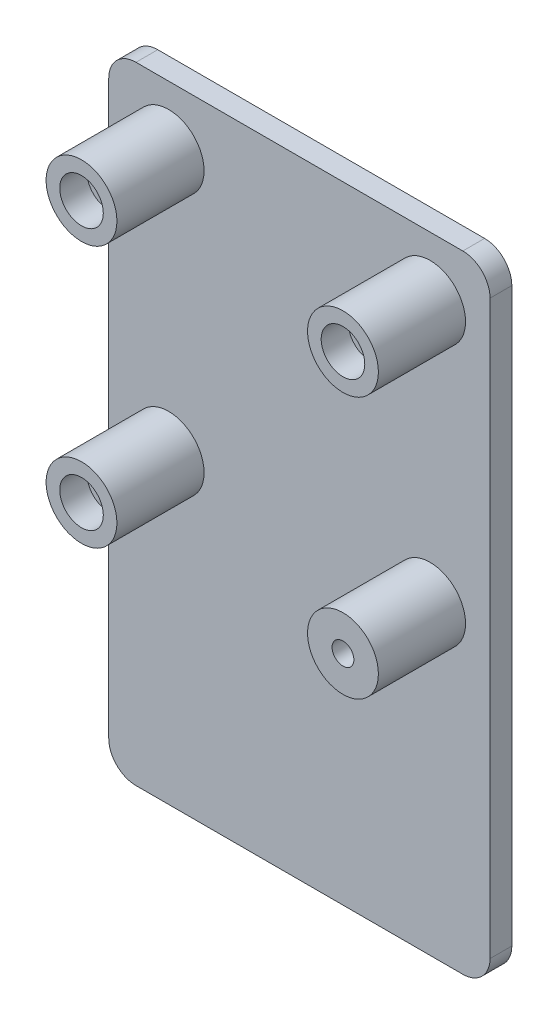
from build123d import *

# Parameters (mm, degrees)
SKETCH1_R           = 6.5
BOSS_EXTRUDE1_DEPTH = 4
SKETCH1_5_R         = 6.5
SKETCH1_5_R_2       = 4
SKETCH1_5_R_3       = 2
BOSS_EXTRUDE2_DEPTH = 20
CUT_EXTRUDE1_START  = 20
SKETCH1_6_R         = 4
SKETCH1_6_R_2       = 2
CUT_EXTRUDE1_DEPTH  = 5


with BuildPart() as part:
    # Sketch1 → Boss-Extrude1 (new body)
    with BuildSketch(Plane.XY):
        with BuildLine():
            Line((-30, 35), (30, 35))
            ThreePointArc((30, 35), (33.535533906, 33.535533906), (35, 30))
            Line((35, 30), (35, -75))
            ThreePointArc((35, -75), (33.535533906, -78.535533906), (30, -80))
            Line((30, -80), (-30, -80))
            ThreePointArc((-30, -80), (-33.535533906, -78.535533906), (-35, -75))
            Line((-35, -75), (-35, 30))
            ThreePointArc((-35, 30), (-33.535533906, 33.535533906), (-30, 35))
        make_face()
        with Locations((24, -24)):
            Circle(SKETCH1_R, mode=Mode.SUBTRACT)
        with Locations((24, 24)):
            Circle(SKETCH1_R, mode=Mode.SUBTRACT)
        with Locations((-24, 24)):
            Circle(SKETCH1_R, mode=Mode.SUBTRACT)
        with Locations((-24, -24)):
            Circle(SKETCH1_R, mode=Mode.SUBTRACT)
    extrude(amount=BOSS_EXTRUDE1_DEPTH)

    # Sketch1_5 → Boss-Extrude2 (add)
    with BuildSketch(Plane.XY):
        with Locations((-24, -24)):
            Circle(SKETCH1_5_R)
        with Locations((-24, -24)):
            Circle(SKETCH1_5_R_2, mode=Mode.SUBTRACT)
        with Locations((-24, -24)):
            Circle(SKETCH1_5_R_2)
        with Locations((-24, -24)):
            Circle(SKETCH1_5_R_3, mode=Mode.SUBTRACT)
        with Locations((24, -24)):
            Circle(SKETCH1_5_R)
        with Locations((24, -24)):
            Circle(SKETCH1_5_R_2, mode=Mode.SUBTRACT)
        with Locations((24, -24)):
            Circle(SKETCH1_5_R_2)
        with Locations((24, -24)):
            Circle(SKETCH1_5_R_3, mode=Mode.SUBTRACT)
        with Locations((24, 24)):
            Circle(SKETCH1_5_R)
        with Locations((24, 24)):
            Circle(SKETCH1_5_R_2, mode=Mode.SUBTRACT)
        with Locations((24, 24)):
            Circle(SKETCH1_5_R_2)
        with Locations((24, 24)):
            Circle(SKETCH1_5_R_3, mode=Mode.SUBTRACT)
        with Locations((-24, 24)):
            Circle(SKETCH1_5_R)
        with Locations((-24, 24)):
            Circle(SKETCH1_5_R_2, mode=Mode.SUBTRACT)
        with Locations((-24, 24)):
            Circle(SKETCH1_5_R_2)
        with Locations((-24, 24)):
            Circle(SKETCH1_5_R_3, mode=Mode.SUBTRACT)
    extrude(amount=BOSS_EXTRUDE2_DEPTH)

    # Sketch1_6 → Cut-Extrude1 (cut)
    with BuildSketch(Plane.XY.offset(CUT_EXTRUDE1_START)):
        with Locations((24, 24)):
            Circle(SKETCH1_6_R)
        with Locations((24, 24)):
            Circle(SKETCH1_6_R_2, mode=Mode.SUBTRACT)
        with Locations((-24, 24)):
            Circle(SKETCH1_6_R)
        with Locations((-24, 24)):
            Circle(SKETCH1_6_R_2, mode=Mode.SUBTRACT)
        with Locations((-24, -24)):
            Circle(SKETCH1_6_R)
        with Locations((-24, -24)):
            Circle(SKETCH1_6_R_2, mode=Mode.SUBTRACT)
        with Locations((24, -24)):
            Circle(SKETCH1_6_R_2)
    extrude(amount=-CUT_EXTRUDE1_DEPTH, mode=Mode.SUBTRACT)


solid = part.part
